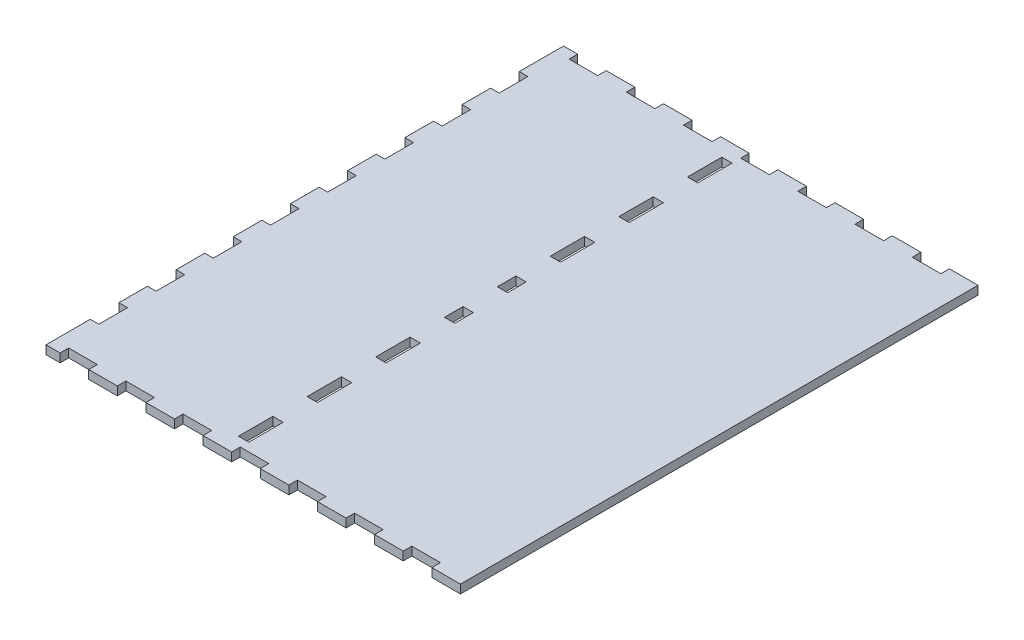
from build123d import *

# Parameters (mm, degrees)
BOSS_EXTRUDE1_DEPTH = 3
SKETCH2_W           = 3.6
SKETCH2_H           = 12
SKETCH2_H_2         = 6.5
CUT_EXTRUDE1_DEPTH  = 10


with BuildPart() as part:
    # Sketch1 → Boss-Extrude1 (new body)
    with BuildSketch(Plane(origin=(0, 0, 0), x_dir=(1, 0, 0), z_dir=(0, 1, 0))):
        Polygon((0, 0), (0, 15.5), (3, 15.5), (3, 25.5), (0, 25.5), (0, 35.5), (3, 35.5), (3, 45.5), (0, 45.5), (0, 55.5), (3, 55.5), (3, 65.5), (0, 65.5), (0, 75.5), (3, 75.5), (3, 85.5), (0, 85.5), (0, 95.5), (3, 95.5), (3, 105.5), (0, 105.5), (0, 115.5), (3, 115.5), (3, 125.5), (0, 125.5), (0, 135.5), (3, 135.5), (3, 145.5), (0, 145.5), (0, 155.5), (3, 155.5), (3, 165.5), (0, 165.5), (0, 181), (4.93, 181), (4.93, 178), (14.93, 178), (14.93, 181), (24.93, 181), (24.93, 178), (34.93, 178), (34.93, 181), (44.93, 181), (44.93, 178), (54.93, 178), (54.93, 181), (64.93, 181), (64.93, 178), (74.93, 178), (74.93, 181), (84.93, 181), (84.93, 178), (94.93, 178), (94.93, 181), (104.93, 181), (104.93, 178), (114.93, 178), (114.93, 181), (124.93, 181), (124.93, 178), (134.93, 178), (134.93, 181), (144.93, 181), (144.93, 0), (134.93, 0), (134.93, 3), (124.93, 3), (124.93, 0), (114.93, 0), (114.93, 3), (104.93, 3), (104.93, 0), (94.93, 0), (94.93, 3), (84.93, 3), (84.93, 0), (74.93, 0), (74.93, 3), (64.93, 3), (64.93, 0), (54.93, 0), (54.93, 3), (44.93, 3), (44.93, 0), (34.93, 0), (34.93, 3), (24.93, 3), (24.93, 0), (14.93, 0), (14.93, 3), (4.93, 3), (4.93, 0), align=None)
    extrude(amount=BOSS_EXTRUDE1_DEPTH)

    # Sketch2 → Cut-Extrude1 (cut)
    with BuildSketch(Plane.XZ):
        with Locations((63.13, -36)):
            Rectangle(SKETCH2_W, SKETCH2_H)
        with Locations((63.13, -12)):
            Rectangle(SKETCH2_W, SKETCH2_H)
        with Locations((63.13, -169)):
            Rectangle(SKETCH2_W, SKETCH2_H)
        with Locations((63.13, -145)):
            Rectangle(SKETCH2_W, SKETCH2_H)
        with Locations((63.13, -121)):
            Rectangle(SKETCH2_W, SKETCH2_H)
        with Locations((63.13, -99.75)):
            Rectangle(SKETCH2_W, SKETCH2_H_2)
        with Locations((63.13, -81.25)):
            Rectangle(SKETCH2_W, SKETCH2_H_2)
        with Locations((63.13, -60)):
            Rectangle(SKETCH2_W, SKETCH2_H)
    extrude(amount=-CUT_EXTRUDE1_DEPTH, mode=Mode.SUBTRACT)


solid = part.part
